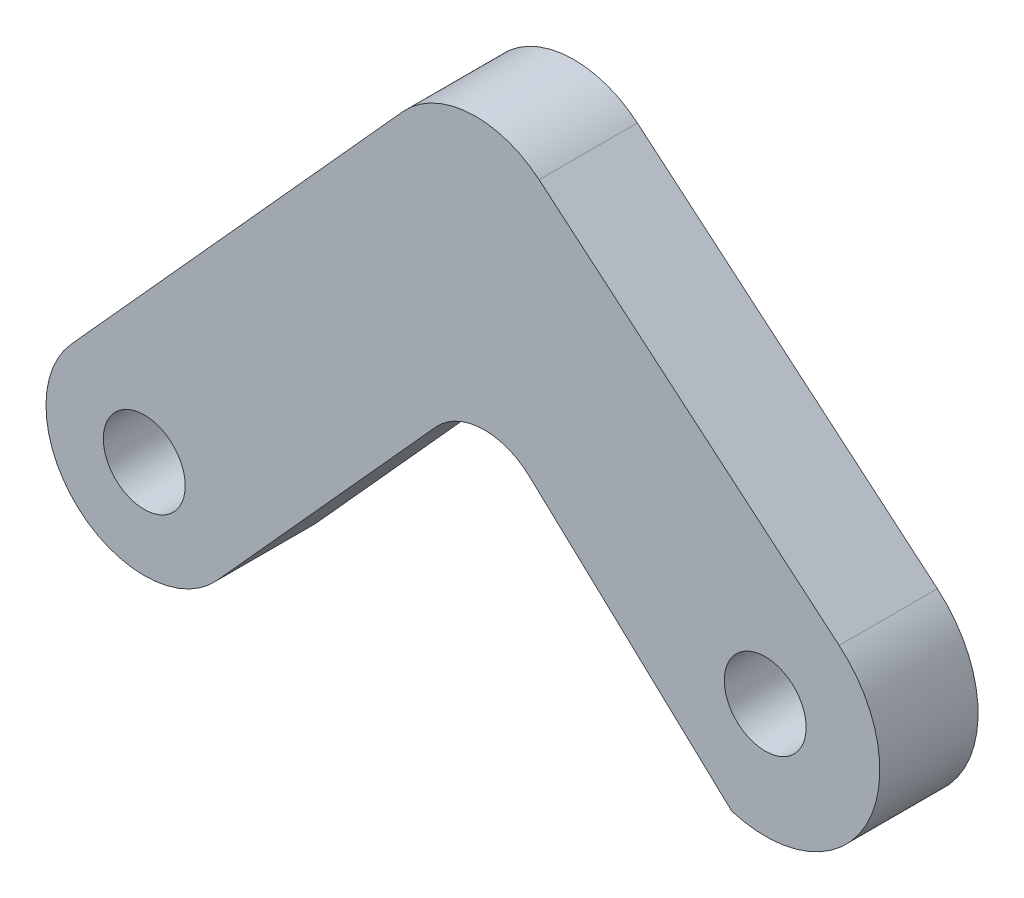
from build123d import *

# Parameters (mm, degrees)
SKETCH1_R           = 1.25
BOSS_EXTRUDE1_DEPTH = 3
FILLET1_R           = 3
FILLET2_R           = 2


with BuildPart() as part:
    # Sketch1 → Boss-Extrude1 (new body)
    with BuildSketch(Plane.XY):
        with BuildLine():
            Line((-0.215618695, 4.237158078), (-12.280236844, -9.121172241))
            ThreePointArc((-12.280236844, -9.121172241), (-12.064618149, -13.358330319), (-7.827460071, -13.142711624))
            Line((-7.827460071, -13.142711624), (0.215618695, -4.237158078))
            Line((0.215618695, -4.237158078), (7.885671037, -11.391188631))
            ThreePointArc((7.885671037, -11.391188631), (11.979783579, -9.716132772), (11.163266713, -5.368619707))
            Line((11.163266713, -5.368619707), (-0.215618695, 4.237158078))
        make_face()
        with Locations((-10.053848457, -11.131941933)):
            Circle(SKETCH1_R, mode=Mode.SUBTRACT)
        with Locations((8.905553546, -8.043078766)):
            Circle(SKETCH1_R, mode=Mode.SUBTRACT)
    extrude(amount=BOSS_EXTRUDE1_DEPTH)

    # Fillet1
    fillet1_edges = [part.edges().sort_by_distance(p)[0] for p in [
        (-0.215618695, 4.237158078, 1.5),
    ]]
    fillet(fillet1_edges, radius=FILLET1_R)

    # Fillet2
    fillet2_edges = [part.edges().sort_by_distance(p)[0] for p in [
        (0.215618695, -4.237158078, 1.5),
    ]]
    fillet(fillet2_edges, radius=FILLET2_R)


solid = part.part
